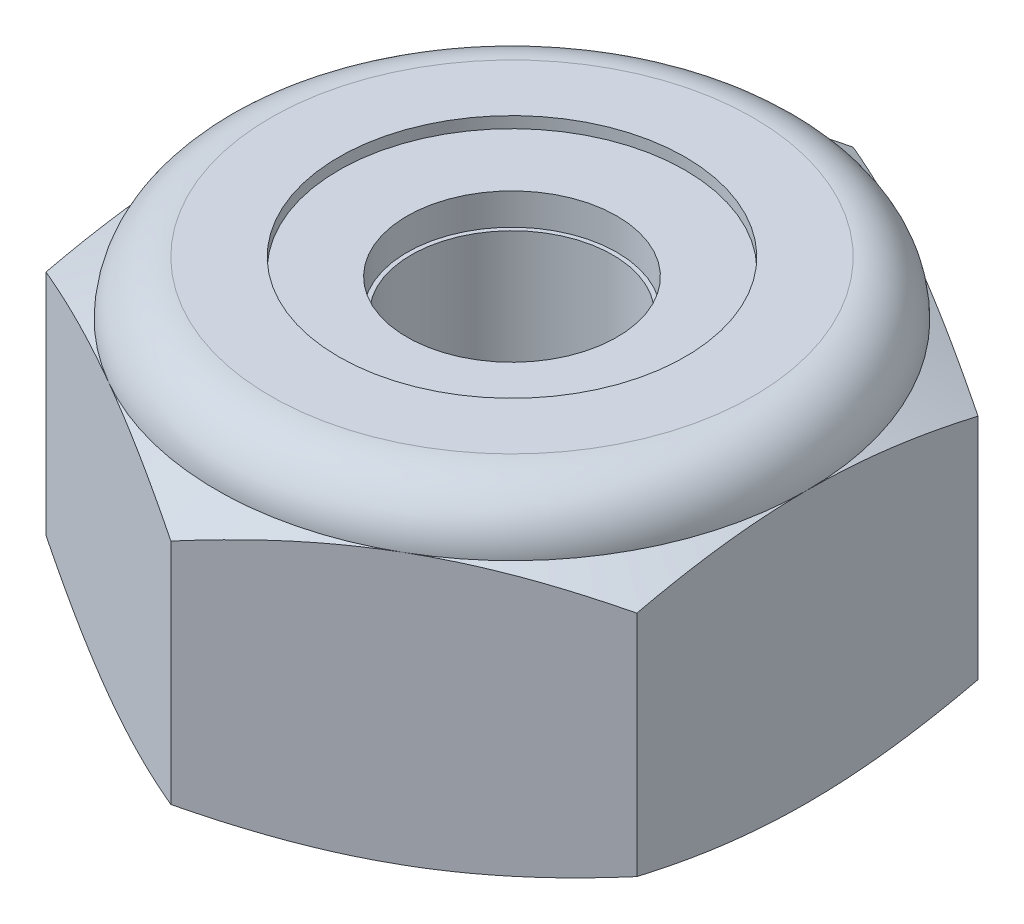
from build123d import *

# Parameters (mm, degrees)
EXTRUDE1_DEPTH      = 4.365625
SKETCH2_W           = 1.7526
SKETCH2_H           = 4.365625
LPATTERN1_COUNT     = 6
LPATTERN1_PITCH     = 0.79375
LPATTERN1_COL_COUNT = 2
LPATTERN1_COL_PITCH = 0.79375
SKETCH8_R           = 2.192732982
BOSS_EXTRUDE1_DEPTH = 3.714221


with BuildPart() as part:
    # Sketch1 → Extrude1 (new body)
    with BuildSketch(Plane(origin=(0, 0, 0), x_dir=(1, 0, 0), z_dir=(0, 1, 0))):
        Polygon((0, 4.582717762), (-3.96875, 2.291358881), (-3.96875, -2.291358881), (0, -4.582717762), (3.96875, -2.291358881), (3.96875, 2.291358881), align=None)
    extrude(amount=EXTRUDE1_DEPTH)

    # Sketch4 → Cut-Revolve2 (revolve, cut)
    with BuildSketch(Plane(origin=(0, 0, 0), x_dir=(0, 0, -1), z_dir=(1, 0, 0))):
        Polygon((0, 4.365625), (1.7526, 4.365625), (1.410275607, 4.205996514), (1.410275607, 0.159628486), (1.7526, 0), (0, 0), align=None)
    revolve(axis=Axis((0, 4.365625, 0), (0, 1, 0)), mode=Mode.SUBTRACT)


with BuildPart() as body_2:
    # Sketch2 → Revolve1 (revolve)
    with BuildSketch(Plane(origin=(0, 0, 0), x_dir=(0, 0, -1), z_dir=(1, 0, 0))):
        with Locations((0.8763, 2.1828125)):
            Rectangle(SKETCH2_W, SKETCH2_H)
    revolve(axis=Axis((0, -1.7526, 0), (0, 1, 0)))

    # Sketch3 → Cut-Revolve1 (revolve, cut)
    with BuildSketch(Plane(origin=(0, 0, 0), x_dir=(0, 0, -1), z_dir=(1, 0, 0))):
        Polygon((1.774513192, 4.268856346), (1.927905533, 3.591475768), (1.454101991, 3.7385105), (1.410275607, 3.932047808), align=None)
    cut_revolve1 = revolve(axis=Axis((0, 4.365625, 0.193538035), (0, -0.975306119, -0.220857364)), mode=Mode.SUBTRACT)

    # LPattern1: Cut-Revolve1 ×6
    with Locations(*[(0, -i * LPATTERN1_PITCH, 0) for i in range(1, LPATTERN1_COUNT)]):
        add(cut_revolve1, mode=Mode.SUBTRACT)

    # LPattern1 col: Cut-Revolve1 ×2
    with Locations(*[(0, i * LPATTERN1_COL_PITCH, 0) for i in range(1, LPATTERN1_COL_COUNT)]):
        add(cut_revolve1, mode=Mode.SUBTRACT)


with BuildPart() as part_1:
    add(part.part)

    # Combine1: cut body 2
    add(body_2.part, mode=Mode.SUBTRACT)

    # Sketch5 → Cut-Revolve3 (revolve, cut)
    with BuildSketch(Plane(origin=(0, 0, 0), x_dir=(0, 0, -1), z_dir=(1, 0, 0))):
        with BuildLine():
            Line((0, 0), (3.96875, 0))
            Line((3.96875, 0), (4.582717762, 0.286297869))
            Line((4.582717762, 0.286297869), (4.582717762, 3.351722964))
            Line((4.582717762, 3.351722964), (3.96875, 3.638020833))
            ThreePointArc((3.96875, 3.638020833), (3.755639674, 4.152514674), (3.241145833, 4.365625))
            Line((3.241145833, 4.365625), (3.241145833, 5.635625))
            Line((3.241145833, 5.635625), (5.852717762, 5.635625))
            Line((5.852717762, 5.635625), (5.852717762, -1.27))
            Line((5.852717762, -1.27), (0, -1.27))
            Line((0, -1.27), (0, 0))
        make_face()
    revolve(axis=Axis((0, 0, 0), (0, 1, 0)), mode=Mode.SUBTRACT)

    # Sketch6 → Cut-Revolve4 (revolve, cut)
    with BuildSketch(Plane(origin=(0, 0, 0), x_dir=(0, 0, -1), z_dir=(1, 0, 0))):
        with BuildLine():
            Line((0, 3.638020833), (3.81635, 3.638020833))
            ThreePointArc((3.81635, 3.638020833), (3.6478766, 4.0447516), (3.241145833, 4.213225))
            Line((3.241145833, 4.213225), (2.32571072, 4.213225))
            Line((2.32571072, 4.213225), (2.32571072, 5.635625))
            Line((2.32571072, 5.635625), (0, 5.635625))
            Line((0, 5.635625), (0, 3.638020833))
        make_face()
    revolve(axis=Axis((0, 5.635625, 0), (0, 1, 0)), mode=Mode.SUBTRACT)



with BuildPart() as body_2_2:
    # Sketch7 → Revolve2 (revolve)
    with BuildSketch(Plane(origin=(0, 0, 0), x_dir=(0, 0, -1), z_dir=(1, 0, 0))):
        with BuildLine():
            Line((1.410275607, 3.714220833), (3.734297654, 3.714220833))
            ThreePointArc((3.734297654, 3.714220833), (3.565938876, 4.016854092), (3.241145833, 4.137025))
            Line((3.241145833, 4.137025), (1.410275607, 4.137025))
            Line((1.410275607, 4.137025), (1.410275607, 3.714220833))
        make_face()
    revolve(axis=Axis((0, 3.714220833, 0), (0, 1, 0)))


with BuildPart() as part_2:
    add(part_1.part)

    add(body_2_2.part)  # Boss-Extrude1 merges body 2 2
    # Sketch8 → Boss-Extrude1 (add)
    with BuildSketch(Plane.XZ):
        Circle(SKETCH8_R)
    extrude(amount=-BOSS_EXTRUDE1_DEPTH)

    # Sketch10 → #6-32 Tapped Hole1 (revolve, cut)
    with BuildSketch(Plane(origin=(0, 3.714220833, 0), x_dir=(0, 0, 1), z_dir=(1, 0, 0))):
        Polygon((0, 0), (0, 3.714220833), (1.98755, 3.714220833), (1.35255, 3.079220833), (1.35255, 0), align=None)
    revolve(axis=Axis((0, 10.064220833, 0), (0, -1, 0)), mode=Mode.SUBTRACT)


solid = part_2.part
